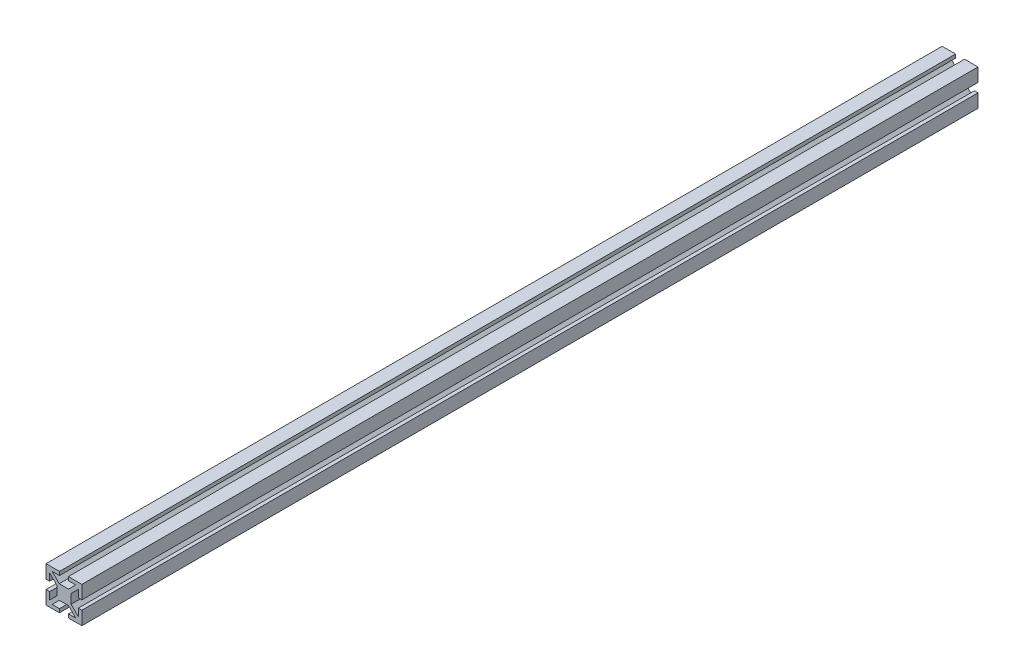
from build123d import *

# Parameters (mm, degrees)
BOSS_EXTRUDE1_DEPTH = 250


with BuildPart() as part:
    # Sketch1 → Boss-Extrude1 (new body, symmetric)
    with BuildSketch(Plane.XY):
        Polygon((-2.585786438, 4), (2.585786438, 4), (6.585786438, 8), (2.5, 8), (2.5, 10), (10, 10), (10, 2.5), (8, 2.5), (8, 6.585786438), (4, 2.585786438), (4, -2.585786438), (8, -6.585786438), (8, -2.5), (10, -2.5), (10, -10), (2.5, -10), (2.5, -8), (6.585786438, -8), (2.585786438, -4), (-2.585786438, -4), (-6.585786438, -8), (-2.5, -8), (-2.5, -10), (-10, -10), (-10, -2.5), (-8, -2.5), (-8, -6.585786438), (-4, -2.585786438), (-4, 2.585786438), (-8, 6.585786438), (-8, 2.5), (-10, 2.5), (-10, 10), (-2.5, 10), (-2.5, 8), (-6.585786438, 8), align=None)
    extrude(amount=BOSS_EXTRUDE1_DEPTH, both=True)


solid = part.part
